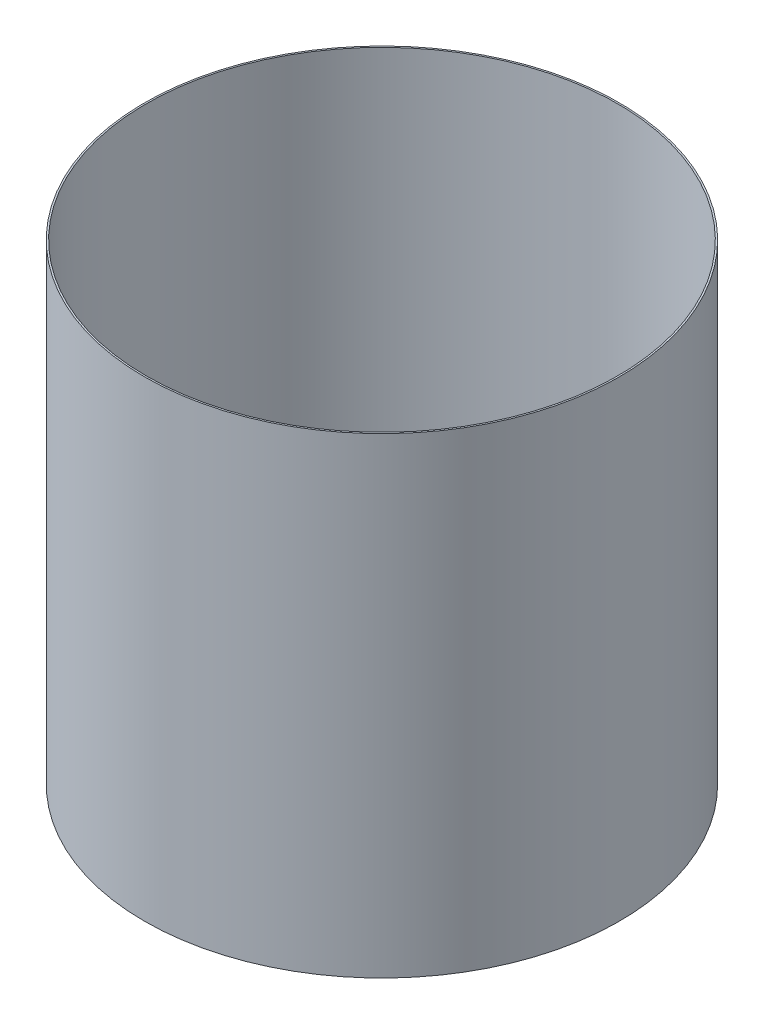
from build123d import *

# Parameters (mm, degrees)
SKETCH6_R           = 230.1875
SKETCH6_R_2         = 228.6
BOSS_EXTRUDE1_DEPTH = 228.6


with BuildPart() as part:
    # Sketch6 → Boss-Extrude1 (new body, symmetric)
    with BuildSketch(Plane(origin=(0, 0, 0), x_dir=(1, 0, 0), z_dir=(0, 1, 0))):
        Circle(SKETCH6_R)
        Circle(SKETCH6_R_2, mode=Mode.SUBTRACT)
    extrude(amount=BOSS_EXTRUDE1_DEPTH, both=True)


solid = part.part
